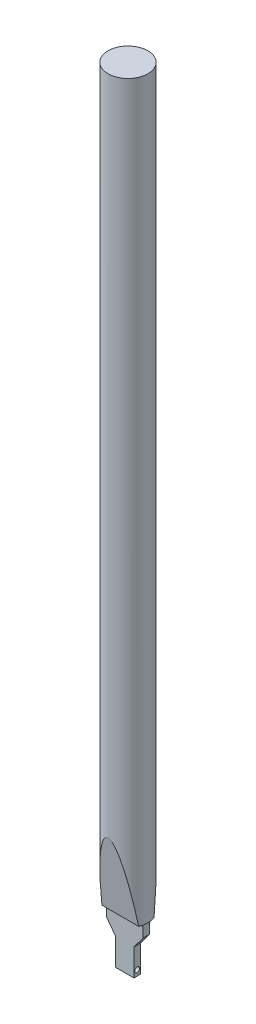
from build123d import *

# Parameters (mm, degrees)
SKETCH1_W           = 3
SKETCH1_H           = 1.05
BOSS_EXTRUDE1_DEPTH = 2.4
SKETCH2_R           = 0.4
CUT_EXTRUDE1_DEPTH  = 3
SKETCH3_W           = 6
SKETCH3_H           = 2
SKETCH3_W_2         = 3
BOSS_EXTRUDE2_DEPTH = 1.05
CUT_EXTRUDE2_REACH  = 10.4
SKETCH4_R           = 0.25
SKETCH5_R           = 3.25
BOSS_EXTRUDE3_DEPTH = 120
FILLET2_R           = 0.5
CUT_EXTRUDE3_DEPTH  = 3.25


with BuildPart() as part:
    # Sketch1 → Boss-Extrude1 (new body)
    with BuildSketch(Plane(origin=(0, 0, 0), x_dir=(1, 0, 0), z_dir=(0, 1, 0))):
        Rectangle(SKETCH1_W, SKETCH1_H)
    extrude(amount=BOSS_EXTRUDE1_DEPTH)

    # Sketch2 → Cut-Extrude1 (cut)
    with BuildSketch(Plane(origin=(1.5, 0, 0), x_dir=(0, 0, -1), z_dir=(1, 0, 0))):
        with Locations((0, 0.9)):
            Circle(SKETCH2_R)
    extrude(amount=-CUT_EXTRUDE1_DEPTH, mode=Mode.SUBTRACT)

    # Sketch3 → Boss-Extrude2 (add)
    with BuildSketch(Plane.XY.offset(0.525)):
        with Locations((0, 7.4)):
            Rectangle(SKETCH3_W, SKETCH3_H)
        Polygon((3, 6.4), (1.5, 4.4), (-1.5, 4.4), (-3, 6.4), align=None)
        with Locations((0, 3.4)):
            Rectangle(SKETCH3_W_2, SKETCH3_H)
    extrude(amount=-BOSS_EXTRUDE2_DEPTH)

    # Sketch4 → Cut-Extrude2 (cut, up to next)
    with BuildSketch(Plane.XZ, mode=Mode.PRIVATE) as cut_extrude2_sk1:
        Circle(SKETCH4_R)
    cut_extrude2_tool1 = extrude(cut_extrude2_sk1.sketch, amount=-CUT_EXTRUDE2_REACH, mode=Mode.PRIVATE) & part.part
    add(cut_extrude2_tool1.solids().sort_by_distance((0, 0, 0))[0], mode=Mode.SUBTRACT)

    # Sketch5 → Boss-Extrude3 (add)
    with BuildSketch(Plane(origin=(0, 8.4, 0), x_dir=(1, 0, 0), z_dir=(0, 1, 0))):
        Circle(SKETCH5_R)
    extrude(amount=BOSS_EXTRUDE3_DEPTH)

    # Fillet2
    fillet2_edges = [part.edges().sort_by_distance(p)[0] for p in [
        (0, 8.4, -0.525),
        (0, 8.4, 0.525),
    ]]
    fillet(fillet2_edges, radius=FILLET2_R)

    # Sketch6 → Cut-Extrude3 (cut, symmetric)
    with BuildSketch(Plane(origin=(0, 0, 0), x_dir=(0, 0, -1), z_dir=(1, 0, 0))):
        Polygon((-3.25, 8.4), (-3.25, 20.4), (-1.25, 8.4), align=None)
        Polygon((3.25, 8.4), (3.25, 20.4), (1.25, 8.4), align=None)
    extrude(amount=CUT_EXTRUDE3_DEPTH, both=True, mode=Mode.SUBTRACT)


solid = part.part
